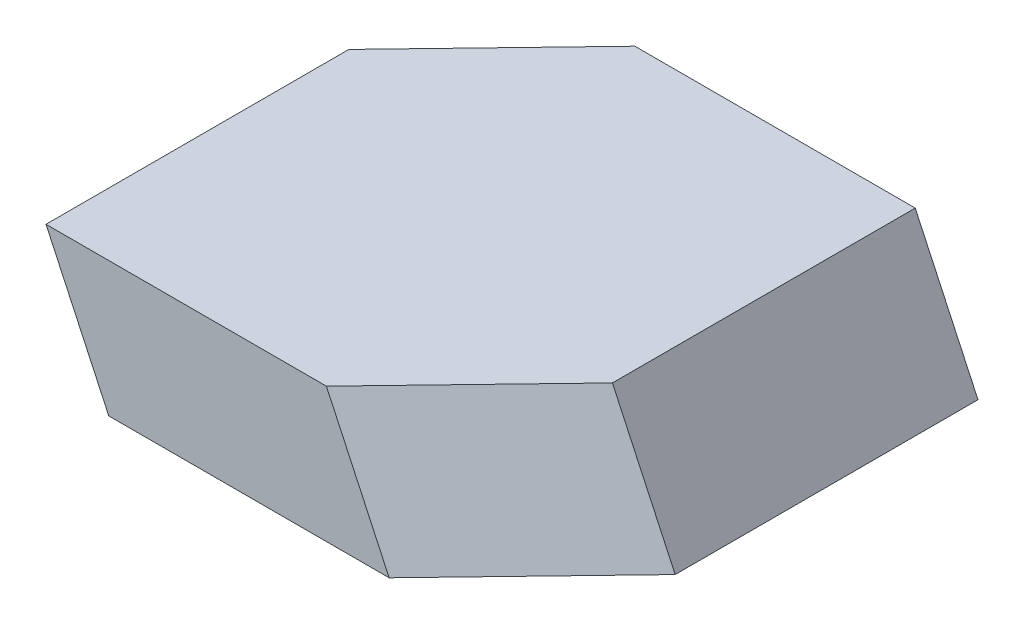
from build123d import *


with BuildPart() as part:
    # Sketch1 → Loft1 section 0
    with BuildSketch(Plane(origin=(0, 0, 0), x_dir=(1, 0, 0), z_dir=(0, 1, 0))):
        Polygon((0, 0), (50, 0), (50, -54), (25, -80), (-25, -80), (-25, -26), align=None)
    # Sketch4 → Loft1 section 1
    with BuildSketch(Plane(origin=(0, 24, 0), x_dir=(-1, 0, 0), z_dir=(0, 1, 0))):
        Polygon((-38.808616204, 0), (-38.808616204, 54), (-13.808616204, 80), (36.191383796, 80), (36.191383796, 26), (11.191383796, 0), align=None)
    loft()


solid = part.part
